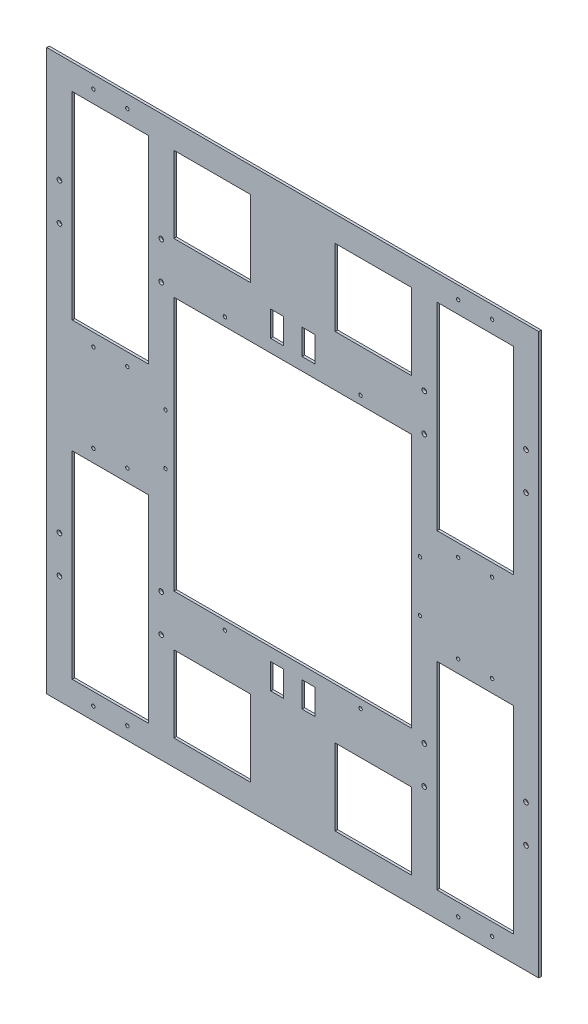
from build123d import *

# Parameters (mm, degrees)
SKETCH_1_W          = 580
SKETCH_1_H          = 660
EXTRUDE_1_DEPTH     = 3
SKETCH_2_W          = 90
SKETCH_2_H          = 233.23
CUT_EXTRUDE_1_DEPTH = 3
SKETCH_3_W          = 90
SKETCH_3_H          = 90
CUT_EXTRUDE_2_DEPTH = 4
SKETCH_4_W          = 280
SKETCH_4_H          = 300
CUT_EXTRUDE_3_DEPTH = 3
SKETCH_5_W          = 15
SKETCH_5_H          = 30
CUT_EXTRUDE_4_DEPTH = 3
SKETCH_6_R          = 2
CUT_EXTRUDE_5_DEPTH = 4
SKETCH_7_R          = 2.75
CUT_EXTRUDE_6_DEPTH = 4
SKETCH_8_R          = 2
CUT_EXTRUDE_7_DEPTH = 3


with BuildPart() as part:
    # 草圖1 → 填料-伸長1 (new body)
    with BuildSketch(Plane.XY):
        with Locations((-114.793886735, -166.775956284)):
            Rectangle(SKETCH_1_W, SKETCH_1_H)
    extrude(amount=EXTRUDE_1_DEPTH)

    # 草圖2 → 除料-伸長1 (cut)
    with BuildSketch(Plane.XY.offset(3)):
        with Locations((-329.793886735, -350.160956284)):
            Rectangle(SKETCH_2_W, SKETCH_2_H)
        with Locations((100.206113265, -350.160956284)):
            Rectangle(SKETCH_2_W, SKETCH_2_H)
        with Locations((100.206113265, 16.609043716)):
            Rectangle(SKETCH_2_W, SKETCH_2_H)
        with Locations((-329.793886735, 16.609043716)):
            Rectangle(SKETCH_2_W, SKETCH_2_H)
    extrude(amount=-CUT_EXTRUDE_1_DEPTH, mode=Mode.SUBTRACT)

    # 草圖3 → 除料-伸長2 (cut, through all)
    with BuildSketch(Plane.XY.offset(3)):
        with Locations((-209.793886735, -421.775956284)):
            Rectangle(SKETCH_3_W, SKETCH_3_H)
        with Locations((-19.793886735, -421.775956284)):
            Rectangle(SKETCH_3_W, SKETCH_3_H)
        with Locations((-19.793886735, 88.224043716)):
            Rectangle(SKETCH_3_W, SKETCH_3_H)
        with Locations((-209.793886735, 88.224043716)):
            Rectangle(SKETCH_3_W, SKETCH_3_H)
    extrude(amount=-CUT_EXTRUDE_2_DEPTH, mode=Mode.SUBTRACT)

    # 草圖4 → 除料-伸長3 (cut)
    with BuildSketch(Plane.XY.offset(3)):
        with Locations((-114.793886735, -166.775956284)):
            Rectangle(SKETCH_4_W, SKETCH_4_H)
    extrude(amount=-CUT_EXTRUDE_3_DEPTH, mode=Mode.SUBTRACT)

    # 草圖5 → 除料-伸長4 (cut)
    with BuildSketch(Plane.XY.offset(3)):
        with Locations((-96.293886735, -346.775956284)):
            Rectangle(SKETCH_5_W, SKETCH_5_H)
        with Locations((-133.293886735, -346.775956284)):
            Rectangle(SKETCH_5_W, SKETCH_5_H)
        with Locations((-133.293886735, 13.224043716)):
            Rectangle(SKETCH_5_W, SKETCH_5_H)
        with Locations((-96.293886735, 13.224043716)):
            Rectangle(SKETCH_5_W, SKETCH_5_H)
    extrude(amount=-CUT_EXTRUDE_4_DEPTH, mode=Mode.SUBTRACT)

    # 草圖6 → 除料-伸長5 (cut, through all)
    with BuildSketch(Plane.XY.offset(3)):
        with Locations((-349.793886735, -218.545956284)):
            Circle(SKETCH_6_R)
        with Locations((-309.793886735, -218.545956284)):
            Circle(SKETCH_6_R)
        with Locations((-309.793886735, -481.775956284)):
            Circle(SKETCH_6_R)
        with Locations((-349.793886735, -481.775956284)):
            Circle(SKETCH_6_R)
        with Locations((80.206113265, -481.775956284)):
            Circle(SKETCH_6_R)
        with Locations((120.206113265, -481.775956284)):
            Circle(SKETCH_6_R)
        with Locations((80.206113265, -218.545956284)):
            Circle(SKETCH_6_R)
        with Locations((120.206113265, -218.545956284)):
            Circle(SKETCH_6_R)
        with Locations((-309.793886735, 148.224043716)):
            Circle(SKETCH_6_R)
        with Locations((-349.793886735, 148.224043716)):
            Circle(SKETCH_6_R)
        with Locations((-309.793886735, -115.005956284)):
            Circle(SKETCH_6_R)
        with Locations((-349.793886735, -115.005956284)):
            Circle(SKETCH_6_R)
        with Locations((80.206113265, -115.005956284)):
            Circle(SKETCH_6_R)
        with Locations((120.206113265, -115.005956284)):
            Circle(SKETCH_6_R)
        with Locations((120.206113265, 148.224043716)):
            Circle(SKETCH_6_R)
        with Locations((80.206113265, 148.224043716)):
            Circle(SKETCH_6_R)
    extrude(amount=-CUT_EXTRUDE_5_DEPTH, mode=Mode.SUBTRACT)

    # 草圖7 → 除料-伸長6 (cut, through all)
    with BuildSketch(Plane.XY.offset(3)):
        with Locations((-389.793886735, -368.775956284)):
            Circle(SKETCH_7_R)
        with Locations((-389.793886735, -324.775956284)):
            Circle(SKETCH_7_R)
        with Locations((-269.793886735, -324.775956284)):
            Circle(SKETCH_7_R)
        with Locations((-269.793886735, -368.775956284)):
            Circle(SKETCH_7_R)
        with Locations((40.206113265, -368.775956284)):
            Circle(SKETCH_7_R)
        with Locations((40.206113265, -324.775956284)):
            Circle(SKETCH_7_R)
        with Locations((160.206113265, -324.775956284)):
            Circle(SKETCH_7_R)
        with Locations((160.206113265, -368.775956284)):
            Circle(SKETCH_7_R)
        with Locations((160.206113265, 35.224043716)):
            Circle(SKETCH_7_R)
        with Locations((160.206113265, -8.775956284)):
            Circle(SKETCH_7_R)
        with Locations((40.206113265, -8.775956284)):
            Circle(SKETCH_7_R)
        with Locations((40.206113265, 35.224043716)):
            Circle(SKETCH_7_R)
        with Locations((-269.793886735, 35.224043716)):
            Circle(SKETCH_7_R)
        with Locations((-269.793886735, -8.775956284)):
            Circle(SKETCH_7_R)
        with Locations((-389.793886735, -8.775956284)):
            Circle(SKETCH_7_R)
        with Locations((-389.793886735, 35.224043716)):
            Circle(SKETCH_7_R)
    extrude(amount=-CUT_EXTRUDE_6_DEPTH, mode=Mode.SUBTRACT)

    # 草圖8 → 除料-伸長7 (cut)
    with BuildSketch(Plane.XY.offset(3)):
        with Locations((-194.793886735, -6.775956284)):
            Circle(SKETCH_8_R)
        with Locations((-34.793886735, -6.775956284)):
            Circle(SKETCH_8_R)
        with Locations((-34.793886735, -326.775956284)):
            Circle(SKETCH_8_R)
        with Locations((-194.793886735, -326.775956284)):
            Circle(SKETCH_8_R)
        with Locations((-264.793886735, -136.775956284)):
            Circle(SKETCH_8_R)
        with Locations((-264.793886735, -196.775956284)):
            Circle(SKETCH_8_R)
        with Locations((35.206113265, -136.775956284)):
            Circle(SKETCH_8_R)
        with Locations((35.206113265, -196.775956284)):
            Circle(SKETCH_8_R)
    extrude(amount=-CUT_EXTRUDE_7_DEPTH, mode=Mode.SUBTRACT)


solid = part.part
